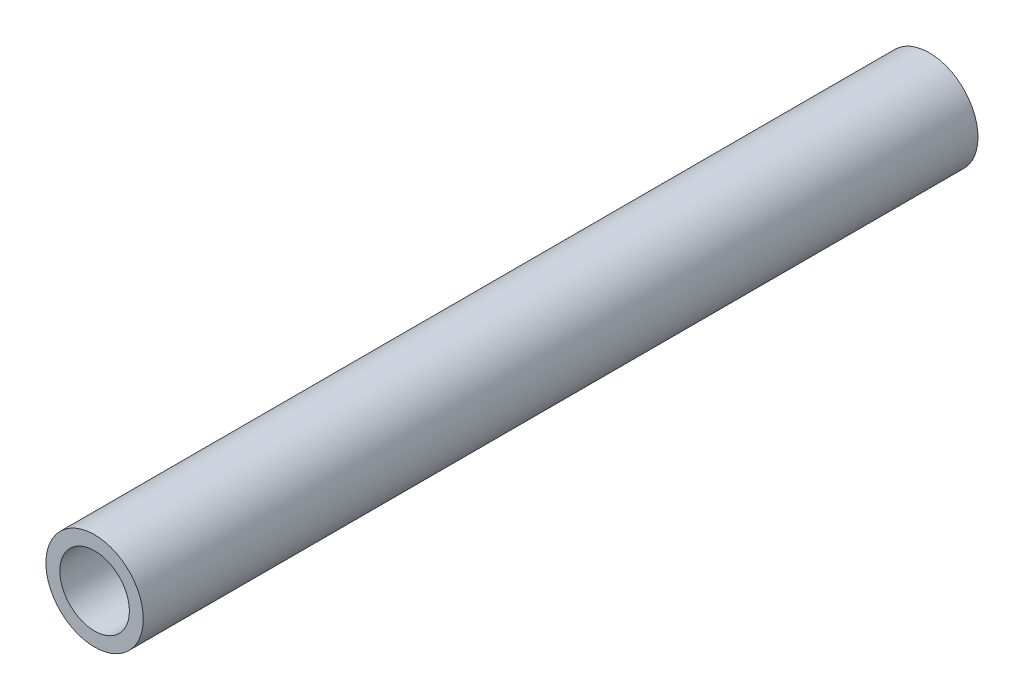
from build123d import *

# Parameters (mm, degrees)
SKETCH1_R           = 13.335
SKETCH1_R_2         = 9.525
BOSS_EXTRUDE1_DEPTH = 228.6


with BuildPart() as part:
    # Sketch1 → Boss-Extrude1 (new body)
    with BuildSketch(Plane.XY):
        Circle(SKETCH1_R)
        Circle(SKETCH1_R_2, mode=Mode.SUBTRACT)
    extrude(amount=BOSS_EXTRUDE1_DEPTH)


solid = part.part
